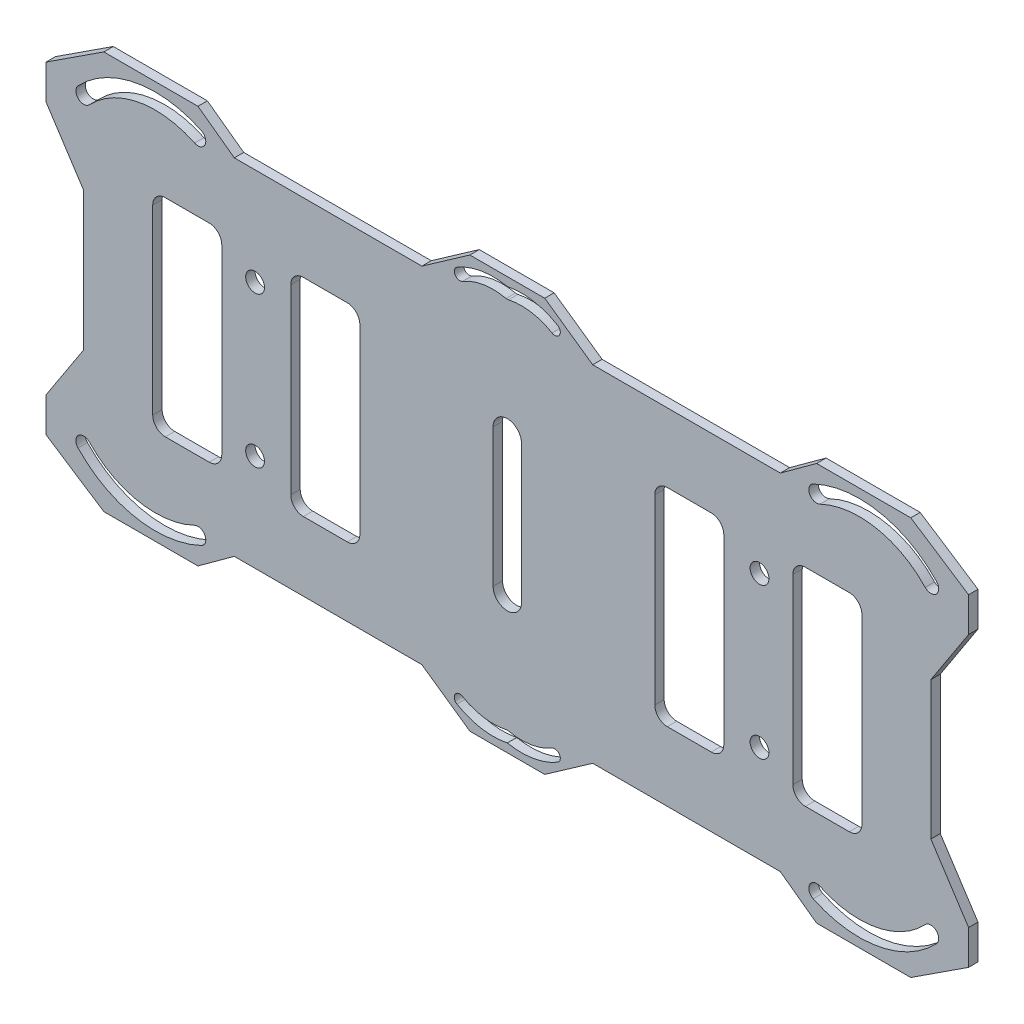
from build123d import *

# Parameters (mm, degrees)
SCHIZZO1_R                   = 1.5
ESTRUSIONE_ESTRUSIONE1_DEPTH = 0.75


with BuildPart() as part:
    # Schizzo1 → Estrusione-Estrusione1 (new body, symmetric)
    with BuildSketch(Plane.XY):
        Polygon((-43.5, -27.5), (-13.615232638, -27.5), (-5.964504028, -32.859521299), (5.964504028, -32.859521299), (13.615232638, -27.5), (43.5, -27.5), (49.293787181, -31.722358535), (64.293787181, -31.722358535), (73.508072858, -25.714285677), (73.508072858, -20.214285677), (67.5, -11), (67.5, 11), (73.508072858, 20.214285677), (73.508072858, 25.714285677), (64.293787181, 31.722358535), (49.293787181, 31.722358535), (43.5, 27.5), (13.615232638, 27.5), (5.964504028, 32.859521299), (-5.964504028, 32.859521299), (-13.615232638, 27.5), (-43.5, 27.5), (-49.293787181, 31.722358535), (-64.293787181, 31.722358535), (-73.508072858, 25.714285677), (-73.508072858, 20.214285677), (-67.5, 11), (-67.5, -11), (-73.508072858, -20.214285677), (-73.508072858, -25.714285677), (-64.293787181, -31.722358535), (-49.293787181, -31.722358535), align=None)
        with BuildLine():
            ThreePointArc((-48.754479002, -28.623738791), (-59.172775767, -30.009764998), (-68.405644393, -24.988200197))
            ThreePointArc((-68.405644393, -24.988200197), (-68.356417198, -23.226138607), (-66.594355607, -23.275365801))
            ThreePointArc((-66.594355607, -23.275365801), (-58.719274878, -27.558458065), (-49.83309536, -26.376261209))
            ThreePointArc((-49.83309536, -26.376261209), (-48.17004839, -26.960691821), (-48.754479002, -28.623738791))
        make_face(mode=Mode.SUBTRACT)
        with Locations((-40.191447808, -12)):
            Circle(SCHIZZO1_R, mode=Mode.SUBTRACT)
        with BuildLine():
            ThreePointArc((0, -31.496185519), (-4.133745369, -31.563971562), (-8.018095478, -30.148249145))
            ThreePointArc((-8.018095478, -30.148249145), (-8.326872952, -28.953648185), (-7.132271992, -28.644870711))
            ThreePointArc((-7.132271992, -28.644870711), (-3.764579281, -29.856257566), (-0.187146253, -29.75240554))
            ThreePointArc((-0.187146253, -29.75240554), (0, -29.732097651), (0.187146253, -29.75240554))
            ThreePointArc((0.187146253, -29.75240554), (3.764579281, -29.856257566), (7.132271992, -28.644870711))
            ThreePointArc((7.132271992, -28.644870711), (8.326872952, -28.953648185), (8.018095478, -30.148249145))
            ThreePointArc((8.018095478, -30.148249145), (4.133745369, -31.563971562), (0, -31.496185519))
        make_face(mode=Mode.SUBTRACT)
        with BuildLine():
            ThreePointArc((66.594355607, -23.275365801), (68.356417198, -23.226138607), (68.405644393, -24.988200197))
            ThreePointArc((68.405644393, -24.988200197), (59.172775767, -30.009764998), (48.754479002, -28.623738791))
            ThreePointArc((48.754479002, -28.623738791), (48.17004839, -26.960691821), (49.83309536, -26.376261209))
            ThreePointArc((49.83309536, -26.376261209), (58.719274878, -27.558458065), (66.594355607, -23.275365801))
        make_face(mode=Mode.SUBTRACT)
        with Locations((40.191447808, -12)):
            Circle(SCHIZZO1_R, mode=Mode.SUBTRACT)
        with BuildLine():
            Line((-47.5, -16.5), (-54.5, -16.5))
            ThreePointArc((-54.5, -16.5), (-55.914213562, -15.914213562), (-56.5, -14.5))
            Line((-56.5, -14.5), (-56.5, 14.5))
            ThreePointArc((-56.5, 14.5), (-55.914213562, 15.914213562), (-54.5, 16.5))
            Line((-54.5, 16.5), (-47.5, 16.5))
            ThreePointArc((-47.5, 16.5), (-46.085786438, 15.914213562), (-45.5, 14.5))
            Line((-45.5, 14.5), (-45.5, -14.5))
            ThreePointArc((-45.5, -14.5), (-46.085786438, -15.914213562), (-47.5, -16.5))
        make_face(mode=Mode.SUBTRACT)
        with Locations((-40.191447808, 12)):
            Circle(SCHIZZO1_R, mode=Mode.SUBTRACT)
        with BuildLine():
            Line((-25.5, -16.5), (-32.5, -16.5))
            ThreePointArc((-32.5, -16.5), (-33.914213562, -15.914213562), (-34.5, -14.5))
            Line((-34.5, -14.5), (-34.5, 14.5))
            ThreePointArc((-34.5, 14.5), (-33.914213562, 15.914213562), (-32.5, 16.5))
            Line((-32.5, 16.5), (-25.5, 16.5))
            ThreePointArc((-25.5, 16.5), (-24.085786438, 15.914213562), (-23.5, 14.5))
            Line((-23.5, 14.5), (-23.5, -14.5))
            ThreePointArc((-23.5, -14.5), (-24.085786438, -15.914213562), (-25.5, -16.5))
        make_face(mode=Mode.SUBTRACT)
        with BuildLine():
            ThreePointArc((-2.261398956, 11), (0, 13.261398956), (2.261398956, 11))
            Line((2.261398956, 11), (2.261398956, -11))
            ThreePointArc((2.261398956, -11), (0, -13.261398956), (-2.261398956, -11))
            Line((-2.261398956, -11), (-2.261398956, 11))
        make_face(mode=Mode.SUBTRACT)
        with BuildLine():
            ThreePointArc((-66.594355607, 23.275365801), (-68.356417198, 23.226138607), (-68.405644393, 24.988200197))
            ThreePointArc((-68.405644393, 24.988200197), (-67.961138694, 25.440973547), (-67.5, 25.876794757))
            ThreePointArc((-67.5, 25.876794757), (-58.546813094, 30.113494239), (-48.754479002, 28.623738791))
            ThreePointArc((-48.754479002, 28.623738791), (-48.17004839, 26.960691821), (-49.83309536, 26.376261209))
            ThreePointArc((-49.83309536, 26.376261209), (-58.719274878, 27.558458065), (-66.594355607, 23.275365801))
        make_face(mode=Mode.SUBTRACT)
        with BuildLine():
            ThreePointArc((25.5, -16.5), (24.085786438, -15.914213562), (23.5, -14.5))
            Line((23.5, -14.5), (23.5, 14.5))
            ThreePointArc((23.5, 14.5), (24.085786438, 15.914213562), (25.5, 16.5))
            Line((25.5, 16.5), (32.5, 16.5))
            ThreePointArc((32.5, 16.5), (33.914213562, 15.914213562), (34.5, 14.5))
            Line((34.5, 14.5), (34.5, -14.5))
            ThreePointArc((34.5, -14.5), (33.914213562, -15.914213562), (32.5, -16.5))
            Line((32.5, -16.5), (25.5, -16.5))
        make_face(mode=Mode.SUBTRACT)
        with BuildLine():
            ThreePointArc((47.5, -16.5), (46.085786438, -15.914213562), (45.5, -14.5))
            Line((45.5, -14.5), (45.5, 14.5))
            ThreePointArc((45.5, 14.5), (46.085786438, 15.914213562), (47.5, 16.5))
            Line((47.5, 16.5), (54.5, 16.5))
            ThreePointArc((54.5, 16.5), (55.914213562, 15.914213562), (56.5, 14.5))
            Line((56.5, 14.5), (56.5, -14.5))
            ThreePointArc((56.5, -14.5), (55.914213562, -15.914213562), (54.5, -16.5))
            Line((54.5, -16.5), (47.5, -16.5))
        make_face(mode=Mode.SUBTRACT)
        with Locations((40.191447808, 12)):
            Circle(SCHIZZO1_R, mode=Mode.SUBTRACT)
        with BuildLine():
            ThreePointArc((0.187146253, 29.75240554), (0, 29.732097651), (-0.187146253, 29.75240554))
            ThreePointArc((-0.187146253, 29.75240554), (-3.764579281, 29.856257566), (-7.132271992, 28.644870711))
            ThreePointArc((-7.132271992, 28.644870711), (-8.326872952, 28.953648185), (-8.018095478, 30.148249145))
            ThreePointArc((-8.018095478, 30.148249145), (-4.133745369, 31.563971562), (0, 31.496185519))
            ThreePointArc((0, 31.496185519), (4.133745369, 31.563971562), (8.018095478, 30.148249145))
            ThreePointArc((8.018095478, 30.148249145), (8.326872952, 28.953648185), (7.132271992, 28.644870711))
            ThreePointArc((7.132271992, 28.644870711), (3.764579281, 29.856257566), (0.187146253, 29.75240554))
        make_face(mode=Mode.SUBTRACT)
        with BuildLine():
            ThreePointArc((48.754479002, 28.623738791), (59.172775767, 30.009764998), (68.405644393, 24.988200197))
            ThreePointArc((68.405644393, 24.988200197), (68.356417198, 23.226138607), (66.594355607, 23.275365801))
            ThreePointArc((66.594355607, 23.275365801), (58.719274878, 27.558458065), (49.83309536, 26.376261209))
            ThreePointArc((49.83309536, 26.376261209), (48.17004839, 26.960691821), (48.754479002, 28.623738791))
        make_face(mode=Mode.SUBTRACT)
    extrude(amount=ESTRUSIONE_ESTRUSIONE1_DEPTH, both=True)


solid = part.part
